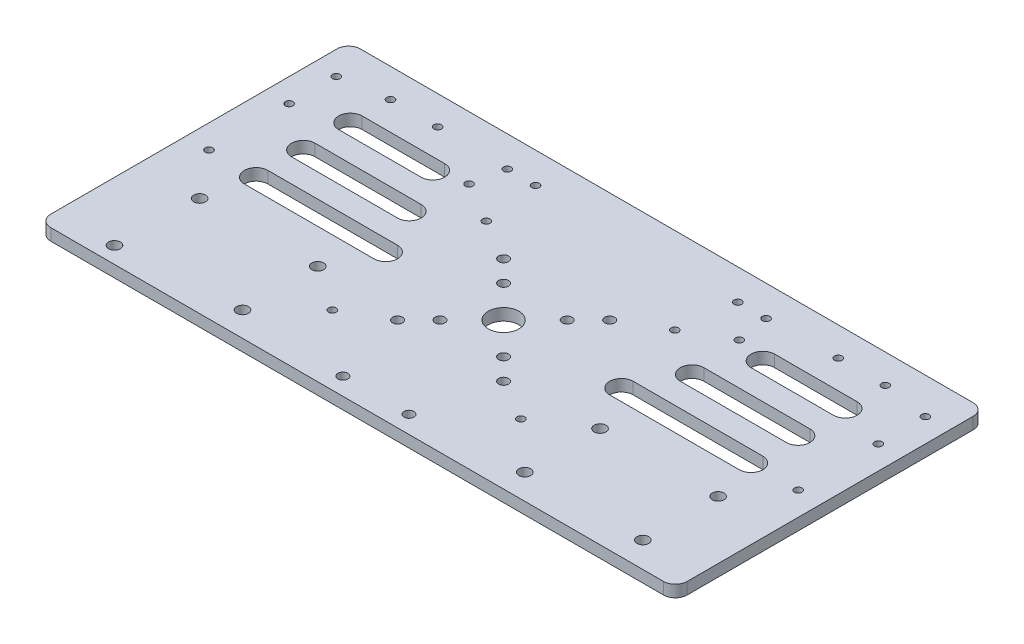
from build123d import *

# Parameters (mm, degrees)
SKETCH_1_W           = 280
SKETCH_1_H           = 130
SKETCH_1_R           = 6.5
EXTRUDE_1_DEPTH      = 5
SKETCH_2_R           = 1.6
CUT_EXTRUDE_1_DEPTH  = 5
SKETCH_3_R           = 2.1
CUT_EXTRUDE_2_DEPTH  = 5
CUT_EXTRUDE_3_DEPTH  = 10
CUT_EXTRUDE_4_DEPTH  = 10
SKETCH_11_R          = 1.6
CUT_EXTRUDE_5_DEPTH  = 10
FILLET_1_R           = 20
FILLET_3_R           = 20
SKETCH_12_W          = 65
SKETCH_12_H          = 60
CUT_EXTRUDE_6_DEPTH  = 10
EXTRUDE_2_DEPTH      = 5
SKETCH_14_W          = 280
SKETCH_14_H          = 4.25
EXTRUDE_3_DEPTH      = 5
EXTRUDE_4_DEPTH      = 5
SKETCH_16_R          = 2.1
CUT_EXTRUDE_7_DEPTH  = 6
EXTRUDE_5_DEPTH      = 5
SKETCH_18_R          = 2.5
SKETCH_18_R_2        = 2.624277209
CUT_EXTRUDE_8_DEPTH  = 6
CUT_EXTRUDE_9_DEPTH  = 6
SKETCH_20_R          = 1.6
CUT_EXTRUDE_10_DEPTH = 6
FILLET_4_R           = 2
EXTRUDE_9_DEPTH      = 5
SKETCH_23_R          = 1.6
CUT_EXTRUDE_11_DEPTH = 6
EXTRUDE_10_DEPTH     = 5
EXTRUDE_11_DEPTH     = 5
SKETCH_26_R          = 1.6
CUT_EXTRUDE_12_DEPTH = 6
SKETCH_27_R          = 2.5
SKETCH_27_R_2        = 2.624277209
EXTRUDE_12_DEPTH     = 5
SKETCH_28_R          = 2.500000007
CUT_EXTRUDE_13_DEPTH = 6
SKETCH_29_W          = 11.387828734
SKETCH_29_H          = 131.363248654
CUT_EXTRUDE_14_DEPTH = 6
SKETCH_30_W          = 12.612171266
SKETCH_30_H          = 131.363248654
CUT_EXTRUDE_15_DEPTH = 5
FILLET_5_R           = 5
CUT_EXTRUDE_16_DEPTH = 5
CUT_EXTRUDE_17_DEPTH = 5


with BuildPart() as part:
    # 草图1 → 凸台-拉伸1 (new body)
    with BuildSketch(Plane(origin=(0, 0, 0), x_dir=(1, 0, 0), z_dir=(0, 1, 0))):
        Rectangle(SKETCH_1_W, SKETCH_1_H)
        Circle(SKETCH_1_R, mode=Mode.SUBTRACT)
    extrude(amount=EXTRUDE_1_DEPTH)

    # 草图2 → 切除-拉伸1 (cut)
    with BuildSketch(Plane(origin=(0, 5, 0), x_dir=(1, 0, 0), z_dir=(0, 1, 0))):
        with Locations((-125, 0)):
            Circle(SKETCH_2_R)
        with Locations((-125, 34)):
            Circle(SKETCH_2_R)
        with Locations((-125, 54)):
            Circle(SKETCH_2_R)
        with Locations((-125, -33)):
            Circle(SKETCH_2_R)
        with Locations((125, 54)):
            Circle(SKETCH_2_R)
        with Locations((125, 34)):
            Circle(SKETCH_2_R)
        with Locations((125, 0)):
            Circle(SKETCH_2_R)
        with Locations((125, -33)):
            Circle(SKETCH_2_R)
    extrude(amount=-CUT_EXTRUDE_1_DEPTH, mode=Mode.SUBTRACT)

    # 草图3 → 切除-拉伸2 (cut)
    with BuildSketch(Plane(origin=(0, 5, 0), x_dir=(1, 0, 0), z_dir=(0, 1, 0))):
        with Locations((-13.5, 13.5)):
            Circle(SKETCH_3_R)
        with Locations((-22.5, 22.5)):
            Circle(SKETCH_3_R)
        with Locations((13.5, 13.5)):
            Circle(SKETCH_3_R)
        with Locations((22.5, 22.5)):
            Circle(SKETCH_3_R)
        with Locations((13.5, -13.5)):
            Circle(SKETCH_3_R)
        with Locations((22.5, -22.5)):
            Circle(SKETCH_3_R)
        with Locations((-13.5, -13.5)):
            Circle(SKETCH_3_R)
        with Locations((-22.5, -22.5)):
            Circle(SKETCH_3_R)
    extrude(amount=-CUT_EXTRUDE_2_DEPTH, mode=Mode.SUBTRACT)

    # 草图7 → 切除-拉伸3 (cut)
    with BuildSketch(Plane.XZ):
        with BuildLine():
            Line((80, -65), (23.49175606, -32.37495015))
            ThreePointArc((23.49175606, -32.37495015), (0, -40), (-23.49175606, -32.37495015))
            Line((-23.49175606, -32.37495015), (-80, -65))
            Line((-80, -65), (80, -65))
        make_face()
        with BuildLine():
            Line((80, 65), (-80, 65))
            Line((-80, 65), (-23.49175606, 32.37495015))
            ThreePointArc((-23.49175606, 32.37495015), (0, 40), (23.49175606, 32.37495015))
            Line((23.49175606, 32.37495015), (80, 65))
        make_face()
    extrude(amount=-CUT_EXTRUDE_3_DEPTH, mode=Mode.SUBTRACT)

    # 草图8 → 切除-拉伸4 (cut)
    with BuildSketch(Plane.XZ):
        with BuildLine():
            Line((105, -5), (50, -5))
            ThreePointArc((50, -5), (45, 0), (50, 5))
            Line((50, 5), (105, 5))
            ThreePointArc((105, 5), (110, 0), (105, -5))
        make_face()
        with BuildLine():
            Line((105, -25), (60, -25))
            ThreePointArc((60, -25), (55, -20), (60, -15))
            Line((60, -15), (105, -15))
            ThreePointArc((105, -15), (110, -20), (105, -25))
        make_face()
        with BuildLine():
            Line((105, -45), (70, -45))
            ThreePointArc((70, -45), (65, -40), (70, -35))
            Line((70, -35), (105, -35))
            ThreePointArc((105, -35), (110, -40), (105, -45))
        make_face()
        with BuildLine():
            Line((105, 45), (70, 45))
            ThreePointArc((70, 45), (65, 40), (70, 35))
            Line((70, 35), (105, 35))
            ThreePointArc((105, 35), (110, 40), (105, 45))
        make_face()
        with BuildLine():
            Line((105, 25), (60, 25))
            ThreePointArc((60, 25), (55, 20), (60, 15))
            Line((60, 15), (105, 15))
            ThreePointArc((105, 15), (110, 20), (105, 25))
        make_face()
        with BuildLine():
            Line((-105, -45), (-70, -45))
            ThreePointArc((-70, -45), (-65, -40), (-70, -35))
            Line((-70, -35), (-105, -35))
            ThreePointArc((-105, -35), (-110, -40), (-105, -45))
        make_face()
        with BuildLine():
            Line((-105, -25), (-60, -25))
            ThreePointArc((-60, -25), (-55, -20), (-60, -15))
            Line((-60, -15), (-105, -15))
            ThreePointArc((-105, -15), (-110, -20), (-105, -25))
        make_face()
        with BuildLine():
            Line((-105, -5), (-50, -5))
            ThreePointArc((-50, -5), (-45, 0), (-50, 5))
            Line((-50, 5), (-105, 5))
            ThreePointArc((-105, 5), (-110, 0), (-105, -5))
        make_face()
        with BuildLine():
            Line((-105, 25), (-60, 25))
            ThreePointArc((-60, 25), (-55, 20), (-60, 15))
            Line((-60, 15), (-105, 15))
            ThreePointArc((-105, 15), (-110, 20), (-105, 25))
        make_face()
        with BuildLine():
            Line((-105, 45), (-70, 45))
            ThreePointArc((-70, 45), (-65, 40), (-70, 35))
            Line((-70, 35), (-105, 35))
            ThreePointArc((-105, 35), (-110, 40), (-105, 45))
        make_face()
    extrude(amount=-CUT_EXTRUDE_4_DEPTH, mode=Mode.SUBTRACT)

    # 草图11 → 切除-拉伸5 (cut)
    with BuildSketch(Plane.XZ):
        with Locations((-105, -57)):
            Circle(SKETCH_11_R)
        with Locations((-85, -57)):
            Circle(SKETCH_11_R)
        with Locations((-57.320508076, -42.668384925)):
            Circle(SKETCH_11_R)
        with Locations((-40, -32.668384925)):
            Circle(SKETCH_11_R)
        with Locations((40, -32.668384925)):
            Circle(SKETCH_11_R)
        with Locations((57.320508076, -42.668384925)):
            Circle(SKETCH_11_R)
        with Locations((105, -57)):
            Circle(SKETCH_11_R)
        with Locations((85, -57)):
            Circle(SKETCH_11_R)
        with Locations((-105, 57)):
            Circle(SKETCH_11_R)
        with Locations((-85, 57)):
            Circle(SKETCH_11_R)
        with Locations((-57.320508076, 42.668384925)):
            Circle(SKETCH_11_R)
        with Locations((-40, 32.668384925)):
            Circle(SKETCH_11_R)
        with Locations((40, 32.668384925)):
            Circle(SKETCH_11_R)
        with Locations((57.320508076, 42.668384925)):
            Circle(SKETCH_11_R)
        with Locations((85, 57)):
            Circle(SKETCH_11_R)
        with Locations((105, 57)):
            Circle(SKETCH_11_R)
    extrude(amount=-CUT_EXTRUDE_5_DEPTH, mode=Mode.SUBTRACT)

    # 圆角1
    fillet_1_edges = [part.edges().sort_by_distance(p)[0] for p in [
        (23.49175606, 2.5, 32.37495015),
        (-23.49175606, 2.5, 32.37495015),
        (-23.49175606, 2.5, -32.37495015),
        (23.49175606, 2.5, -32.37495015),
    ]]
    fillet(fillet_1_edges, radius=FILLET_1_R)

    # 圆角3
    fillet_3_edges = [part.edges().sort_by_distance(p)[0] for p in [
        (80, 2.5, 65),
        (-80, 2.5, 65),
        (80, 2.5, -65),
        (-80, 2.5, -65),
    ]]
    fillet(fillet_3_edges, radius=FILLET_3_R)

    # 草图12 → 切除-拉伸6 (cut)
    with BuildSketch(Plane(origin=(0, 5, 0), x_dir=(1, 0, 0), z_dir=(0, 1, 0))):
        with Locations((107.5, -35)):
            Rectangle(SKETCH_12_W, SKETCH_12_H)
        with Locations((-107.5, -35)):
            Rectangle(SKETCH_12_W, SKETCH_12_H)
    extrude(amount=-CUT_EXTRUDE_6_DEPTH, mode=Mode.SUBTRACT)

    # 草图13 → 凸台-拉伸2 (add)
    with BuildSketch(Plane(origin=(0, 5, 0), x_dir=(1, 0, 0), z_dir=(0, 1, 0))):
        with BuildLine():
            Line((-75.358983849, 62.320508076), (-33.232756245, 37.998919229))
            ThreePointArc((-33.232756245, 37.998919229), (-24.491846537, 35.35909936), (-15.488504163, 36.879618203))
            ThreePointArc((-15.488504163, 36.879618203), (0, 40), (15.488504163, 36.879618203))
            ThreePointArc((15.488504163, 36.879618203), (24.491846537, 35.35909936), (33.232756245, 37.998919229))
            Line((33.232756245, 37.998919229), (75.358983849, 62.320508076))
            ThreePointArc((75.358983849, 62.320508076), (80.182602947, 64.318516526), (85.358983849, 65))
            Line((85.358983849, 65), (-85.358983849, 65))
            ThreePointArc((-85.358983849, 65), (-80.182602947, 64.318516526), (-75.358983849, 62.320508076))
        make_face()
    extrude(amount=-EXTRUDE_2_DEPTH)

    # 草图14 → 凸台-拉伸3 (add)
    with BuildSketch(Plane.XZ):
        with Locations((0, -67.125)):
            Rectangle(SKETCH_14_W, SKETCH_14_H)
    extrude(amount=-EXTRUDE_3_DEPTH)

    # 草图15 → 凸台-拉伸4 (add)
    with BuildSketch(Plane.XZ):
        with BuildLine():
            ThreePointArc((70, 35), (65, 40), (70, 45))
            Line((70, 45), (75, 45))
            Line((75, 45), (75, 62.113248654))
            Line((75, 62.113248654), (140, 62.113248654))
            Line((140, 62.113248654), (140, 58.72417686))
            Line((140, 58.72417686), (140, 5))
            Line((140, 5), (75, 5))
            Line((75, 5), (75, 15))
            Line((75, 15), (60, 15))
            ThreePointArc((60, 15), (55, 20), (60, 25))
            Line((60, 25), (75, 25))
            Line((75, 25), (75, 35))
            Line((75, 35), (70, 35))
        make_face()
        with BuildLine():
            ThreePointArc((-15.488504163, 36.879618203), (-24.491846537, 35.35909936), (-33.232756245, 37.998919229))
            Line((-33.232756245, 37.998919229), (-75, 62.113248654))
            Line((-75, 62.113248654), (75, 62.113248654))
            Line((75, 62.113248654), (33.232756245, 37.998919229))
            ThreePointArc((33.232756245, 37.998919229), (24.491846537, 35.35909936), (15.488504163, 36.879618203))
            ThreePointArc((15.488504163, 36.879618203), (0, 40), (-15.488504163, 36.879618203))
        make_face()
        with BuildLine():
            Line((-75, 35), (-70, 35))
            ThreePointArc((-70, 35), (-65, 40), (-70, 45))
            Line((-70, 45), (-75, 45))
            Line((-75, 45), (-75, 62.113248654))
            Line((-75, 62.113248654), (-140, 62.113248654))
            Line((-140, 62.113248654), (-140, 5))
            Line((-140, 5), (-75, 5))
            Line((-75, 5), (-75, 15))
            Line((-75, 15), (-60, 15))
            ThreePointArc((-60, 15), (-55, 20), (-60, 25))
            Line((-60, 25), (-75, 25))
            Line((-75, 25), (-75, 35))
        make_face()
    extrude(amount=-EXTRUDE_4_DEPTH)

    # 草图16 → 切除-拉伸7 (cut, through all)
    with BuildSketch(Plane(origin=(0, 5, 0), x_dir=(1, 0, 0), z_dir=(0, 1, 0))):
        with Locations((-13.5, -54.699438526)):
            Circle(SKETCH_16_R)
        with Locations((14.552949421, -54.699438526)):
            Circle(SKETCH_16_R)
    extrude(amount=-CUT_EXTRUDE_7_DEPTH, mode=Mode.SUBTRACT)

    # 草图17 → 凸台-拉伸5 (add)
    with BuildSketch(Plane(origin=(0, 5, 0), x_dir=(1, 0, 0), z_dir=(0, 1, 0))):
        Polygon((-140, -62.113248654), (-147.612171266, -62.120539425), (-147.612171266, 69.25), (-140, 69.25), align=None)
        Polygon((140, 69.25), (140, -62.113248654), (146.387828734, -62.120539425), (146.387828734, 69.25), align=None)
    extrude(amount=-EXTRUDE_5_DEPTH)

    # 草图18 → 切除-拉伸8 (cut, through all)
    with BuildSketch(Plane(origin=(0, 5, 0), x_dir=(1, 0, 0), z_dir=(0, 1, 0))):
        with Locations((120, -23.120539425)):
            Circle(SKETCH_18_R)
        with Locations((89.387828734, -55.244816634)):
            Circle(SKETCH_18_R_2)
        with Locations((110.403764842, -51.28929314)):
            Circle(SKETCH_18_R)
        with Locations((170, -23.120539425)):
            Circle(SKETCH_18_R)
        with Locations((-59.173598242, -19.68553879)):
            Circle(SKETCH_18_R)
        with Locations((-59.098808662, -51.685451392)):
            Circle(SKETCH_18_R)
        with Locations((-110, -55.120539425)):
            Circle(SKETCH_18_R)
        with Locations((-109.173461682, -19.802397509)):
            Circle(SKETCH_18_R)
    extrude(amount=-CUT_EXTRUDE_8_DEPTH, mode=Mode.SUBTRACT)

    # 草图19 → 切除-拉伸9 (cut, through all)
    with BuildSketch(Plane(origin=(0, 5, 0), x_dir=(1, 0, 0), z_dir=(0, 1, 0))):
        with BuildLine():
            Line((114.693914367, -34.120539425), (144.693914367, -34.120539425))
            ThreePointArc((144.693914367, -34.120539425), (149.693914367, -39.120539425), (144.693914367, -44.120539425))
            Line((144.693914367, -44.120539425), (114.693914367, -44.120539425))
            ThreePointArc((114.693914367, -44.120539425), (109.693914367, -39.120539425), (114.693914367, -34.120539425))
        make_face()
        with BuildLine():
            Line((-130.612171266, -34.120539425), (-39.387828734, -34.120539425))
            ThreePointArc((-39.387828734, -34.120539425), (-34.387828734, -39.120539425), (-39.387828734, -44.120539425))
            Line((-39.387828734, -44.120539425), (-130.612171266, -44.120539425))
            ThreePointArc((-130.612171266, -44.120539425), (-135.612171266, -39.120539425), (-130.612171266, -34.120539425))
        make_face()
        with BuildLine():
            Line((-20.612171266, -34.120539425), (80.612171266, -34.120539425))
            ThreePointArc((80.612171266, -34.120539425), (85.612171266, -39.120539425), (80.612171266, -44.120539425))
            Line((80.612171266, -44.120539425), (-20.612171266, -44.120539425))
            ThreePointArc((-20.612171266, -44.120539425), (-25.612171266, -39.120539425), (-20.612171266, -34.120539425))
        make_face()
    extrude(amount=-CUT_EXTRUDE_9_DEPTH, mode=Mode.SUBTRACT)

    # 草图20 → 切除-拉伸10 (cut, through all)
    with BuildSketch(Plane(origin=(0, 5, 0), x_dir=(1, 0, 0), z_dir=(0, 1, 0))):
        with Locations((-42.68887774, 56.25)):
            Circle(SKETCH_20_R)
        with Locations((-54.68887774, 56.25)):
            Circle(SKETCH_20_R)
        with Locations((43.134082896, 56.25)):
            Circle(SKETCH_20_R)
        with Locations((55.134082896, 56.25)):
            Circle(SKETCH_20_R)
    extrude(amount=-CUT_EXTRUDE_10_DEPTH, mode=Mode.SUBTRACT)

    # 圆角4
    fillet_4_edges = [part.edges().sort_by_distance(p)[0] for p in [
        (-147.612171266, 2.5, 62.120539425),
        (-147.612171266, 2.5, -69.25),
        (146.387828734, 2.5, -69.25),
        (146.387828734, 2.5, 62.120539425),
    ]]
    fillet(fillet_4_edges, radius=FILLET_4_R)

    # 草图22 → 凸台-拉伸9 (add)
    with BuildSketch(Plane(origin=(0, 5, 0), x_dir=(1, 0, 0), z_dir=(0, 1, 0))):
        Polygon((-130.612171266, -34.120539425), (-33.773635594, -34.120539425), (-33.773635594, -44.424171032), (-136.28455359, -44.424171032), (-136.28455359, -34.120539425), align=None)
    extrude(amount=-EXTRUDE_9_DEPTH)

    # 草图23 → 切除-拉伸11 (cut, through all)
    with BuildSketch(Plane(origin=(0, 5, 0), x_dir=(1, 0, 0), z_dir=(0, 1, 0))):
        with Locations((-40, -32.668384925)):
            Circle(SKETCH_23_R)
    extrude(amount=-CUT_EXTRUDE_11_DEPTH, mode=Mode.SUBTRACT)

    # 草图24 → 凸台-拉伸10 (add)
    with BuildSketch(Plane(origin=(0, 5, 0), x_dir=(1, 0, 0), z_dir=(0, 1, 0))):
        Polygon((-20.612171266, -34.120539425), (87.35551584, -34.120539425), (87.35551584, -44.83560988), (-26.412316295, -44.83560988), (-26.412316295, -34.120539425), align=None)
    extrude(amount=-EXTRUDE_10_DEPTH)

    # 草图25 → 凸台-拉伸11 (add)
    with BuildSketch(Plane(origin=(0, 5, 0), x_dir=(1, 0, 0), z_dir=(0, 1, 0))):
        Polygon((114.693914367, -34.120539425), (146.387828734, -34.120539425), (146.387828734, -44.589523886), (108.618617033, -44.589523886), (108.618617033, -33.647045262), align=None)
    extrude(amount=-EXTRUDE_11_DEPTH)

    # 草图26 → 切除-拉伸12 (cut, through all)
    with BuildSketch(Plane(origin=(0, 5, 0), x_dir=(1, 0, 0), z_dir=(0, 1, 0))):
        with Locations((40, -32.668384925)):
            Circle(SKETCH_26_R)
    extrude(amount=-CUT_EXTRUDE_12_DEPTH, mode=Mode.SUBTRACT)

    # 草图27 → 凸台-拉伸12 (add)
    with BuildSketch(Plane(origin=(0, 5, 0), x_dir=(1, 0, 0), z_dir=(0, 1, 0))):
        with Locations((120, -23.120539425)):
            Circle(SKETCH_27_R)
        with Locations((110.403764842, -51.28929314)):
            Circle(SKETCH_27_R)
        with Locations((89.387828734, -55.244816634)):
            Circle(SKETCH_27_R_2)
    extrude(amount=-EXTRUDE_12_DEPTH)

    # 草图28 → 切除-拉伸13 (cut, through all)
    with BuildSketch(Plane(origin=(0, 5, 0), x_dir=(1, 0, 0), z_dir=(0, 1, 0))):
        with Locations((110.328975234, -19.289380538)):
            Circle(SKETCH_28_R)
        with Locations((110.403764842, -51.28929314)):
            Circle(SKETCH_28_R)
        with Locations((60.403901402, -51.406151903)):
            Circle(SKETCH_28_R)
        with Locations((60.329111794, -19.406239302)):
            Circle(SKETCH_28_R)
    extrude(amount=-CUT_EXTRUDE_13_DEPTH, mode=Mode.SUBTRACT)

    # 草图29 → 切除-拉伸14 (cut, through all)
    with BuildSketch(Plane(origin=(0, 5, 0), x_dir=(1, 0, 0), z_dir=(0, 1, 0))):
        with Locations((140.693914367, 3.568375673)):
            Rectangle(SKETCH_29_W, SKETCH_29_H)
    extrude(amount=-CUT_EXTRUDE_14_DEPTH, mode=Mode.SUBTRACT)

    # 草图30 → 切除-拉伸15 (cut)
    with BuildSketch(Plane(origin=(0, 5, 0), x_dir=(1, 0, 0), z_dir=(0, 1, 0))):
        with Locations((-141.306085633, 3.568375673)):
            Rectangle(SKETCH_30_W, SKETCH_30_H)
    extrude(amount=-CUT_EXTRUDE_15_DEPTH, mode=Mode.SUBTRACT)

    # 圆角5
    fillet_5_edges = [part.edges().sort_by_distance(p)[0] for p in [
        (-135, 2.5, -69.25),
        (135, 2.5, 62.113248654),
        (135, 2.5, -69.25),
        (-135, 2.5, 62.113248654),
    ]]
    fillet(fillet_5_edges, radius=FILLET_5_R)

    # 草图31 → 切除-拉伸16 (cut)
    with BuildSketch(Plane(origin=(0, 5, 0), x_dir=(1, 0, 0), z_dir=(0, 1, 0))):
        Polygon((140, -62.113248654), (144.385812482, -61.884800209), (145.499369349, -62.113248654), (140, -62.689805716), align=None)
    extrude(amount=-CUT_EXTRUDE_16_DEPTH, mode=Mode.SUBTRACT)

    # 草图32 → 切除-拉伸17 (cut)
    with BuildSketch(Plane(origin=(0, 5, 0), x_dir=(1, 0, 0), z_dir=(0, 1, 0))):
        Polygon((-145.806700882, -61.654042144), (-145.865181406, -62.693489559), (-139.457024987, -62.598752963), (-139.518564745, -61.467732603), align=None)
    extrude(amount=-CUT_EXTRUDE_17_DEPTH, mode=Mode.SUBTRACT)


solid = part.part
